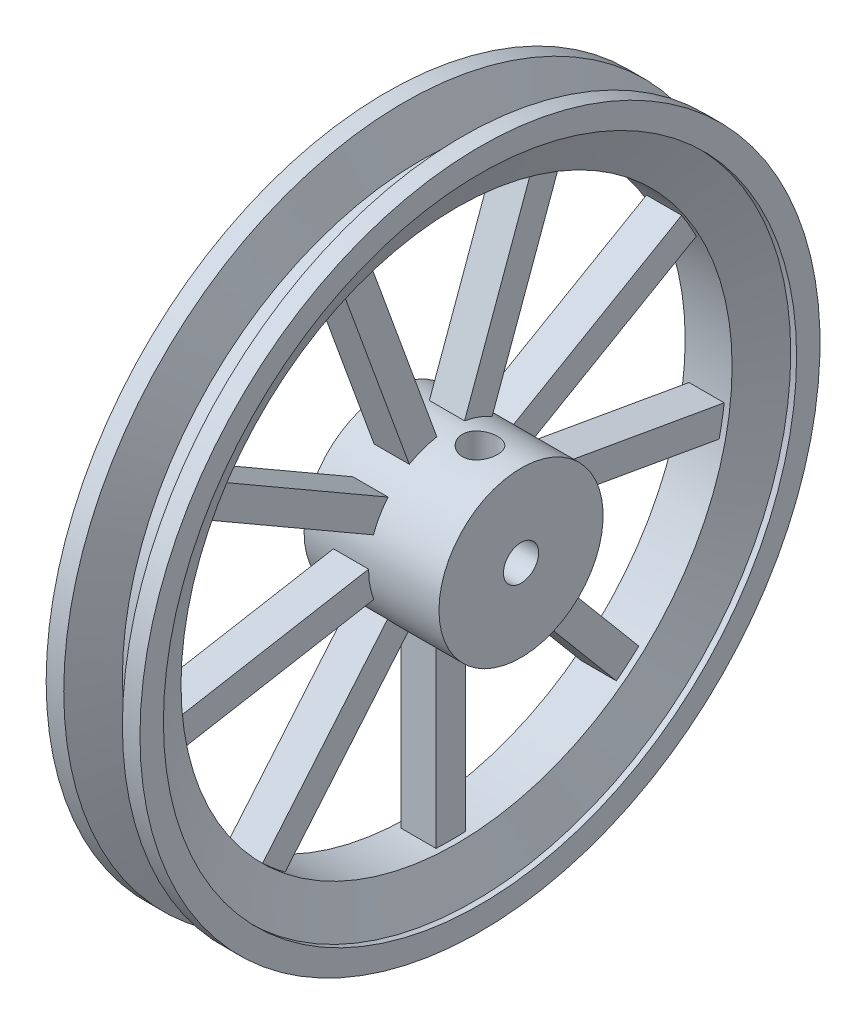
from build123d import *

# Parameters (mm, degrees)
CUT_EXTRUDE1_DEPTH = 35.925
CIRPATTERN2_COUNT  = 9
CUT_EXTRUDE2_START = -44.45
SKETCH3_R          = 9.525
CUT_EXTRUDE2_DEPTH = 44.45


with BuildPart() as part:
    # Sketch1 → Revolve2 (revolve)
    with BuildSketch(Plane.XY):
        Polygon((47.625, 9.525), (-25.4, 9.525), (-25.4, 44.45), (-9.525, 44.45), (-9.525, 149.225), (-12.7, 149.225), (-22.225, 171.45), (-25.4, 171.45), (-25.4, 184.15), (-15.875, 184.15), (-6.35, 161.925), (6.35, 161.925), (15.875, 184.15), (25.4, 184.15), (25.4, 171.45), (22.225, 171.45), (12.7, 149.225), (9.525, 149.225), (9.525, 44.45), (47.625, 44.45), align=None)
    revolve(axis=Axis((-229.110116, 0, 0), (1, 0, 0)))

    # Sketch2 → Cut-Extrude1 (cut, through all)
    with BuildSketch(Plane(origin=(9.525, 0, 0), x_dir=(0, 0, -1), z_dir=(1, 0, 0))):
        with BuildLine():
            Line((-7.49963, 43.812761), (-43.506893, 142.741903))
            ThreePointArc((-43.506893, 142.741903), (0, 149.225), (43.506893, 142.741903))
            Line((43.506893, 142.741903), (7.49963, 43.812761))
            ThreePointArc((7.49963, 43.812761), (0, 44.45), (-7.49963, 43.812761))
        make_face()
    cut_extrude1 = extrude(amount=-CUT_EXTRUDE1_DEPTH, mode=Mode.SUBTRACT)

    # CirPattern2: Cut-Extrude1 ×9 about axis
    cirpattern2_axis = Axis((0, 0, 0), (1, 0, 0))
    for i in range(1, CIRPATTERN2_COUNT):
        add(cut_extrude1.rotate(cirpattern2_axis, i * 360 / CIRPATTERN2_COUNT), mode=Mode.SUBTRACT)

    # Sketch3 → Cut-Extrude2 (cut)
    with BuildSketch(Plane(origin=(0, 44.45, 0), x_dir=(1, 0, 0), z_dir=(0, 1, 0)).offset(CUT_EXTRUDE2_START)):
        with Locations((25.4, 0)):
            Circle(SKETCH3_R)
    extrude(amount=CUT_EXTRUDE2_DEPTH, mode=Mode.SUBTRACT)


solid = part.part
